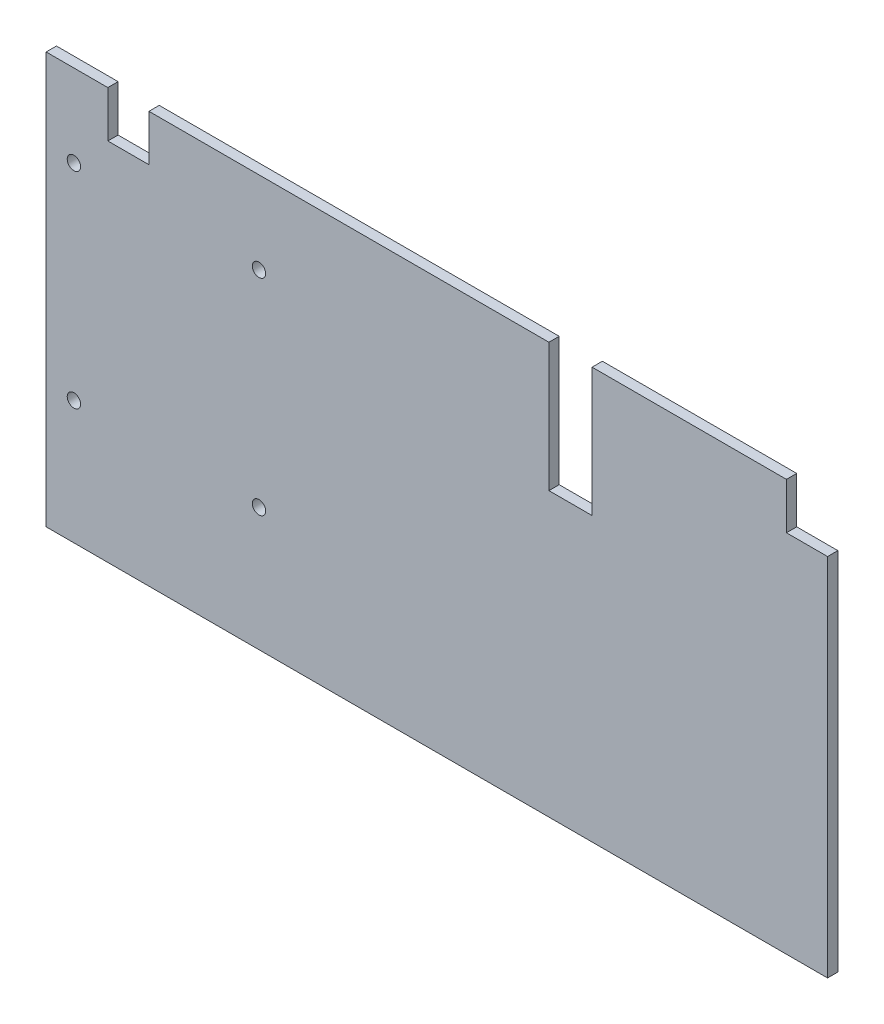
from build123d import *

# Parameters (mm, degrees)
SKETCH1_R           = 6.5
BOSS_EXTRUDE1_DEPTH = 10


with BuildPart() as part:
    # Sketch1 → Boss-Extrude1 (new body)
    with BuildSketch(Plane.XY):
        Polygon((-21, 55), (21, 55), (21, 180), (210, 180), (210, 135), (250, 135), (250, -220), (-510, -220), (-510, 180), (-450, 180), (-450, 135), (-410, 135), (-410, 180), (-21, 180), align=None)
        with Locations((-303, 100)):
            Circle(SKETCH1_R, mode=Mode.SUBTRACT)
        with Locations((-483, 100)):
            Circle(SKETCH1_R, mode=Mode.SUBTRACT)
        with Locations((-303, -100)):
            Circle(SKETCH1_R, mode=Mode.SUBTRACT)
        with Locations((-483, -100)):
            Circle(SKETCH1_R, mode=Mode.SUBTRACT)
    extrude(amount=BOSS_EXTRUDE1_DEPTH)


solid = part.part
